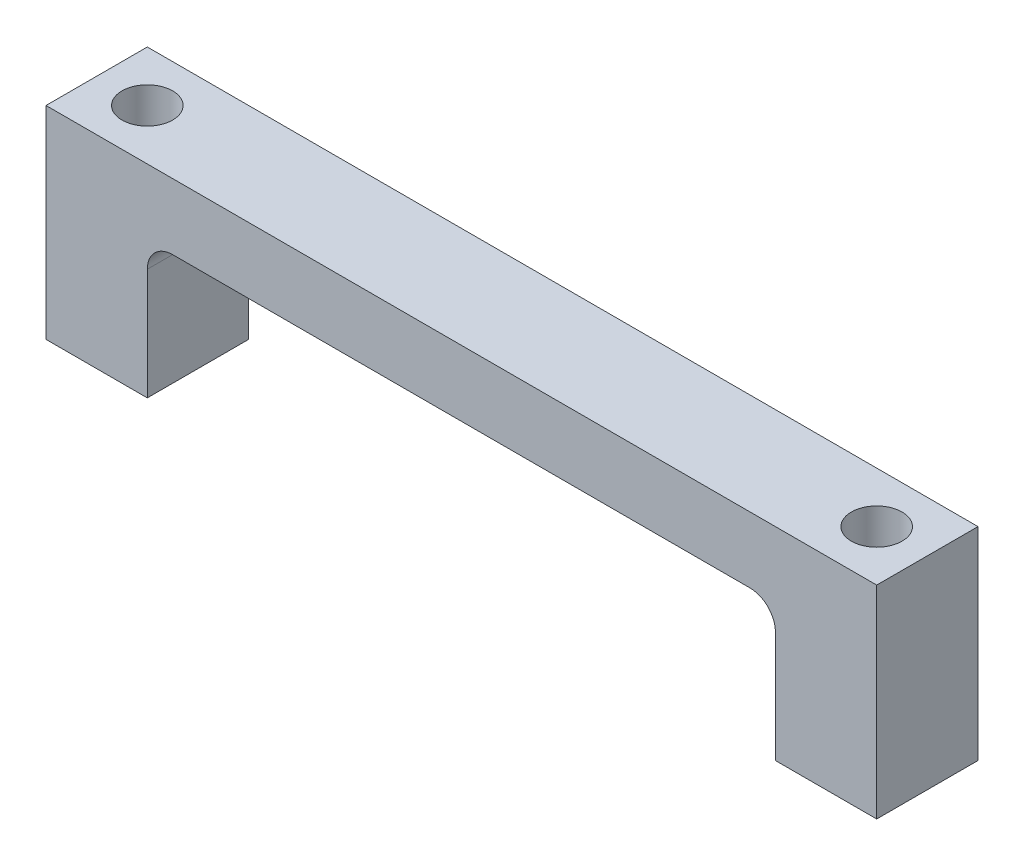
from build123d import *

# Parameters (mm, degrees)
BOSS_EXTRUDE1_DEPTH = 10
FILLET1_R           = 2.5
CUT_EXTRUDE1_REACH  = 22
SKETCH2_R           = 2.5


with BuildPart() as part:
    # Sketch1 → Boss-Extrude1 (new body)
    with BuildSketch(Plane.XY):
        Polygon((0, 6.5), (0, 0), (31, 0), (31, -13.5), (41, -13.5), (41, 6.5), align=None)
        Polygon((-31, 0), (0, 0), (0, 6.5), (-41, 6.5), (-41, -13.5), (-31, -13.5), align=None)
    extrude(amount=BOSS_EXTRUDE1_DEPTH)

    # Fillet1
    fillet1_edges = [part.edges().sort_by_distance(p)[0] for p in [
        (31, 0, 5),
        (-31, 0, 5),
    ]]
    fillet(fillet1_edges, radius=FILLET1_R)

    # Sketch2 → Cut-Extrude1 (cut, up to next)
    with BuildSketch(Plane(origin=(0, 6.5, 0), x_dir=(1, 0, 0), z_dir=(0, 1, 0)), mode=Mode.PRIVATE) as cut_extrude1_sk1:
        with Locations((-36, -5)):
            Circle(SKETCH2_R)
    cut_extrude1_tool1 = extrude(cut_extrude1_sk1.sketch, amount=-CUT_EXTRUDE1_REACH, mode=Mode.PRIVATE) & part.part
    add(cut_extrude1_tool1.solids().sort_by_distance((-36, 6.5, 5))[0], mode=Mode.SUBTRACT)
    # Sketch2 → Cut-Extrude1 (cut, up to next)
    with BuildSketch(Plane(origin=(0, 6.5, 0), x_dir=(1, 0, 0), z_dir=(0, 1, 0)), mode=Mode.PRIVATE) as cut_extrude1_sk2:
        with Locations((36, -5)):
            Circle(SKETCH2_R)
    cut_extrude1_tool2 = extrude(cut_extrude1_sk2.sketch, amount=-CUT_EXTRUDE1_REACH, mode=Mode.PRIVATE) & part.part
    add(cut_extrude1_tool2.solids().sort_by_distance((36, 6.5, 5))[0], mode=Mode.SUBTRACT)


solid = part.part
